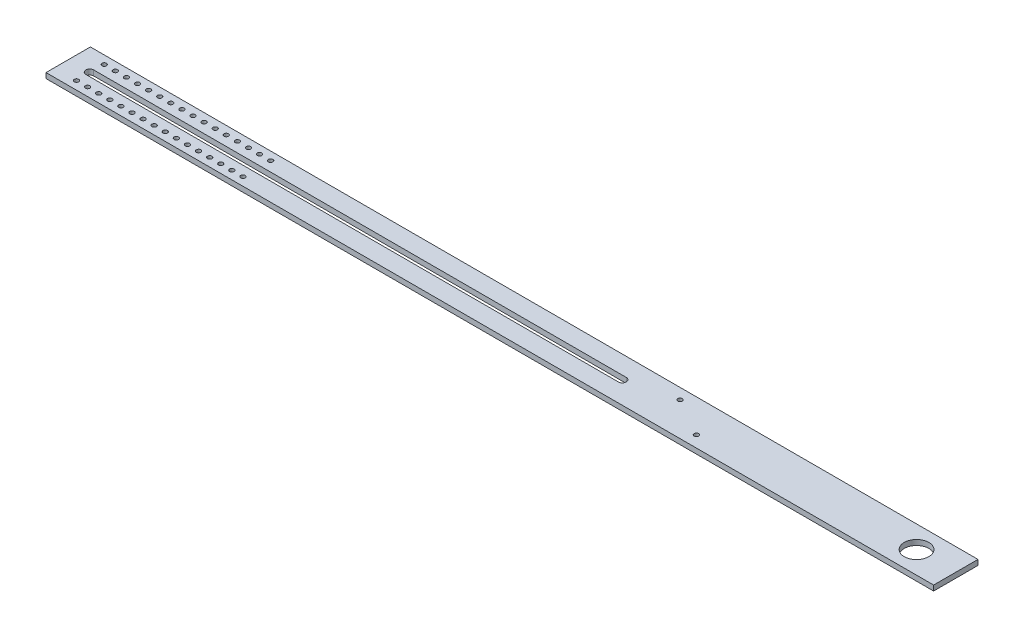
from build123d import *

# Parameters (mm, degrees)
SKETCH1_W               = 1016
SKETCH1_H               = 50.8
BOSS_EXTRUDE1_DEPTH     = 6
CUT_EXTRUDE1_DEPTH      = 6
SKETCH3_R               = 14.097
CUT_EXTRUDE2_DEPTH      = 7
F_1_4_20_TAPPED_HOLE1_D = 5.1054
LPATTERN1_COUNT         = 16
LPATTERN1_PITCH         = 12.7
LPATTERN1_COUNT_DIR2    = 2
LPATTERN1_PITCH_DIR2    = 31.75
F_1_4_20_TAPPED_HOLE2_D = 5.1054


with BuildPart() as part:
    # Sketch1 → Boss-Extrude1 (new body)
    with BuildSketch(Plane(origin=(0, 0, 0), x_dir=(1, 0, 0), z_dir=(0, 1, 0))):
        with Locations((508, 25.4)):
            Rectangle(SKETCH1_W, SKETCH1_H)
    extrude(amount=BOSS_EXTRUDE1_DEPTH)

    # Sketch2 → Cut-Extrude1 (cut)
    with BuildSketch(Plane(origin=(0, 6, 0), x_dir=(1, 0, 0), z_dir=(0, 1, 0))):
        with BuildLine():
            Line((24.7, 29.9), (634.3, 29.9))
            ThreePointArc((634.3, 29.9), (638.8, 25.4), (634.3, 20.9))
            Line((634.3, 20.9), (24.7, 20.9))
            ThreePointArc((24.7, 20.9), (20.2, 25.4), (24.7, 29.9))
        make_face()
    extrude(amount=-CUT_EXTRUDE1_DEPTH, mode=Mode.SUBTRACT)

    # Sketch3 → Cut-Extrude2 (cut, through all)
    with BuildSketch(Plane(origin=(0, 6, 0), x_dir=(1, 0, 0), z_dir=(0, 1, 0))):
        with Locations((971.042, 25.4)):
            Circle(SKETCH3_R)
    extrude(amount=-CUT_EXTRUDE2_DEPTH, mode=Mode.SUBTRACT)

    # 1/4-20 Tapped Hole1 (through all)
    with Locations(Plane(origin=(0, 6, 0), x_dir=(1, 0, 0), z_dir=(0, 1, 0))):
        with Locations((25.4, 41.275)):
            f_1_4_20_tapped_hole1 = Hole(F_1_4_20_TAPPED_HOLE1_D / 2)

    # LPattern1: 1_4-20 Tapped Hole1 16 × 2
    with Locations(*[(i * LPATTERN1_PITCH, 0, j * LPATTERN1_PITCH_DIR2) for i in range(LPATTERN1_COUNT) for j in range(LPATTERN1_COUNT_DIR2) if (i, j) != (0, 0)]):
        add(f_1_4_20_tapped_hole1, mode=Mode.SUBTRACT)

    # 1/4-20 Tapped Hole2 (through all)
    with Locations(Plane(origin=(0, 6, 0), x_dir=(1, 0, 0), z_dir=(0, 1, 0))):
        with Locations((687.318420147, 38.490597432), (731.312510659, 13.090597432)):
            Hole(F_1_4_20_TAPPED_HOLE2_D / 2)


solid = part.part
